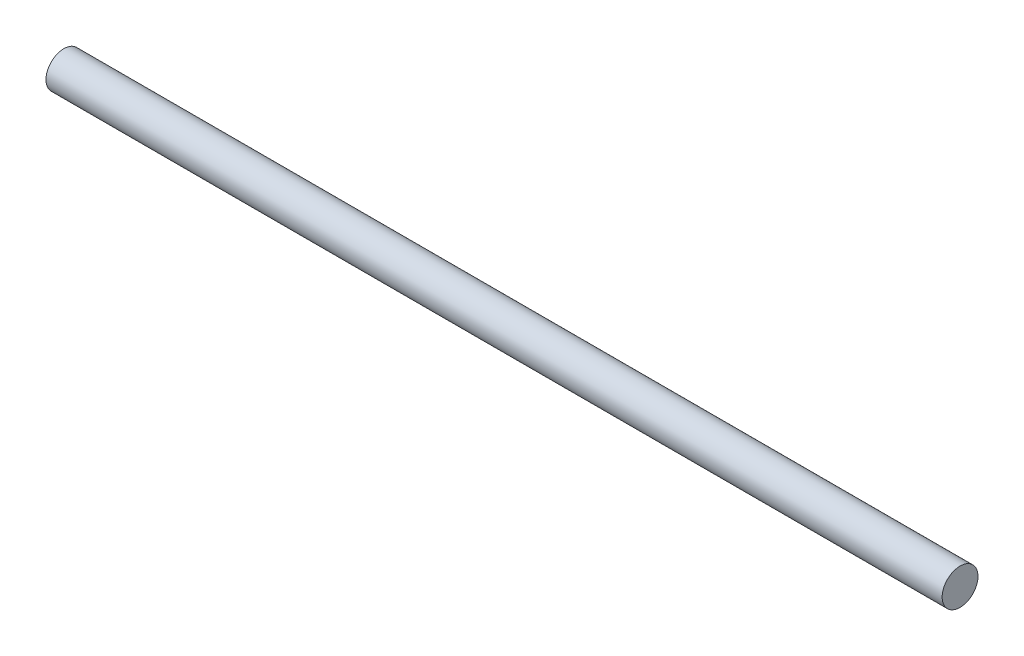
from build123d import *

# Parameters (mm, degrees)
SKETCH2_R           = 10
BOSS_EXTRUDE1_DEPTH = 500


with BuildPart() as part:
    # Sketch2 → Boss-Extrude1 (new body)
    with BuildSketch(Plane(origin=(0, 0, 0), x_dir=(0, 0, -1), z_dir=(1, 0, 0))):
        Circle(SKETCH2_R)
    extrude(amount=BOSS_EXTRUDE1_DEPTH)


solid = part.part
